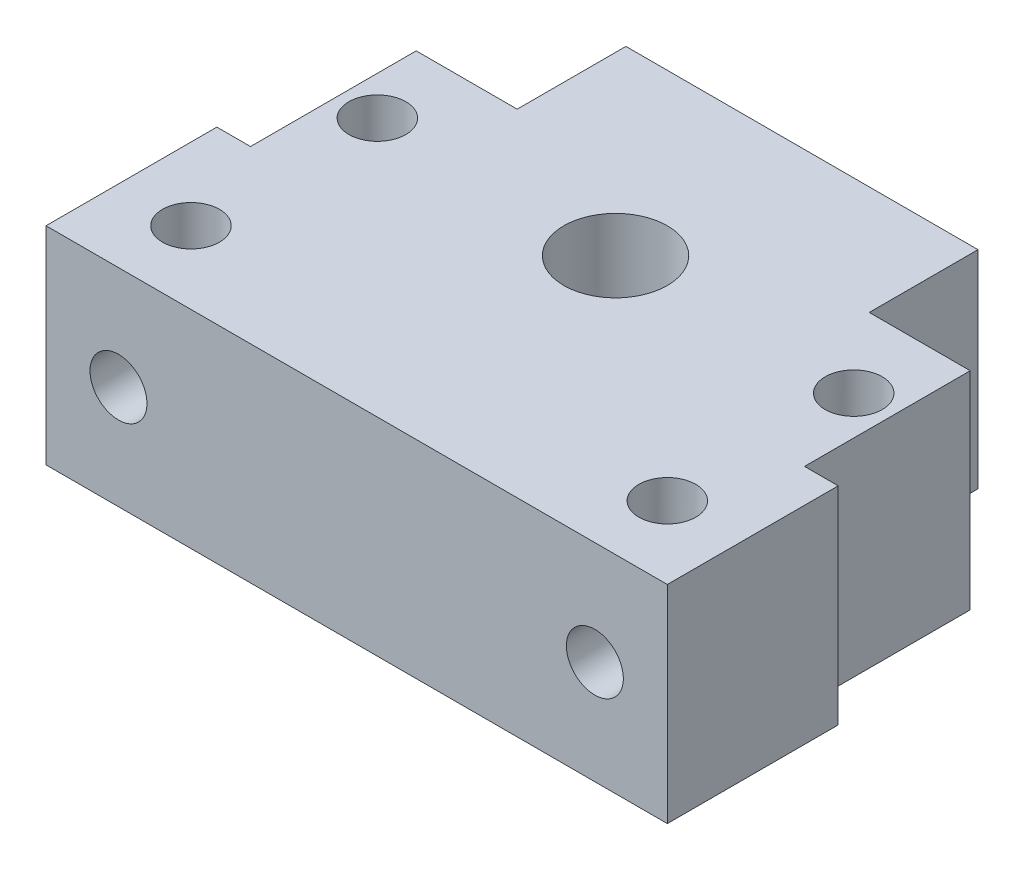
from build123d import *

# Parameters (mm, degrees)
SKETCH1_R           = 5
SKETCH1_R_2         = 2.75
BOSS_EXTRUDE1_DEPTH = 20
SKETCH2_R           = 2.75
CUT_EXTRUDE1_DEPTH  = 33.5
SKETCH3_W           = 6.5
SKETCH3_H           = 32
CUT_EXTRUDE2_DEPTH  = 21


with BuildPart() as part:
    # Sketch1 → Boss-Extrude1 (new body)
    with BuildSketch(Plane(origin=(0, 0, 0), x_dir=(1, 0, 0), z_dir=(0, 1, 0))):
        Polygon((30, -21.5), (-30, -21.5), (-30, 11), (-17, 11), (-17, 21.5), (17, 21.5), (17, 11), (30, 11), align=None)
        with Locations((0, 3.5)):
            Circle(SKETCH1_R, mode=Mode.SUBTRACT)
        with Locations((-23, 3.5)):
            Circle(SKETCH1_R_2, mode=Mode.SUBTRACT)
        with Locations((-23, -14.5)):
            Circle(SKETCH1_R_2, mode=Mode.SUBTRACT)
        with Locations((23, 3.5)):
            Circle(SKETCH1_R_2, mode=Mode.SUBTRACT)
        with Locations((23, -14.5)):
            Circle(SKETCH1_R_2, mode=Mode.SUBTRACT)
    extrude(amount=BOSS_EXTRUDE1_DEPTH)

    # Sketch2 → Cut-Extrude1 (cut, through all)
    with BuildSketch(Plane(origin=(0, 0, -11), x_dir=(-1, 0, 0), z_dir=(0, 0, -1))):
        with Locations((-23, 10)):
            Circle(SKETCH2_R)
        with Locations((23, 10)):
            Circle(SKETCH2_R)
    extrude(amount=-CUT_EXTRUDE1_DEPTH, mode=Mode.SUBTRACT)

    # Sketch3 → Cut-Extrude2 (cut, through all)
    with BuildSketch(Plane.XZ):
        with Locations((30, -11)):
            Rectangle(SKETCH3_W, SKETCH3_H)
        with Locations((-30, -11)):
            Rectangle(SKETCH3_W, SKETCH3_H)
    extrude(amount=-CUT_EXTRUDE2_DEPTH, mode=Mode.SUBTRACT)


solid = part.part
